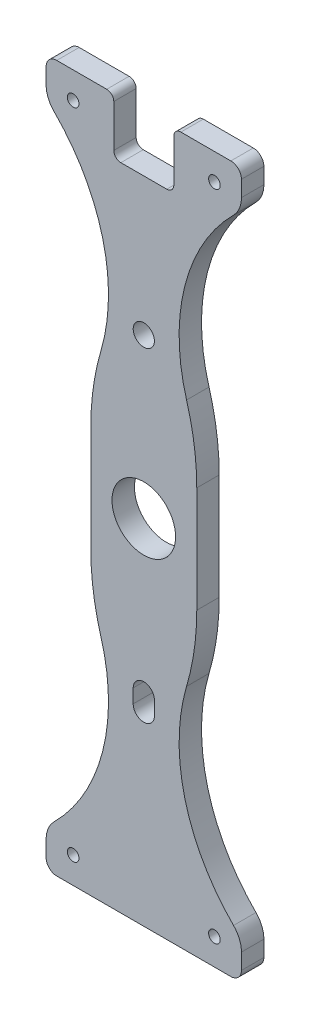
from build123d import *

# Parameters (mm, degrees)
SKETCH1_R           = 9
SKETCH1_R_2         = 3
SKETCH1_R_3         = 1.65
BOSS_EXTRUDE1_DEPTH = 6.35
CUT_EXTRUDE1_DEPTH  = 10
FILLET1_R           = 2


with BuildPart() as part:
    # Sketch1 → Boss-Extrude1 (new body)
    with BuildSketch(Plane.XY):
        with BuildLine():
            Line((-15, 15), (-15, -15))
            ThreePointArc((-15, -15), (-14.275727836, -25.159324804), (-12.117561222, -35.113156605))
            ThreePointArc((-12.117561222, -35.113156605), (-11.640196728, -62.923473964), (-25.409366876, -87.090633124))
            ThreePointArc((-25.409366876, -87.090633124), (-27.067678424, -89.572471742), (-27.65, -92.5))
            Line((-27.65, -92.5), (-27.65, -97))
            ThreePointArc((-27.65, -97), (-26.771320344, -99.121320344), (-24.65, -100))
            Line((-24.65, -100), (24.65, -100))
            ThreePointArc((24.65, -100), (26.771320344, -99.121320344), (27.65, -97))
            Line((27.65, -97), (27.65, -92.5))
            ThreePointArc((27.65, -92.5), (27.067678424, -89.572471742), (25.409366876, -87.090633124))
            ThreePointArc((25.409366876, -87.090633124), (11.640196728, -62.923473964), (12.117561222, -35.113156605))
            ThreePointArc((12.117561222, -35.113156605), (14.275727836, -25.159324804), (15, -15))
            Line((15, -15), (15, 15))
            ThreePointArc((15, 15), (14.275727836, 25.159324804), (12.117561222, 35.113156605))
            ThreePointArc((12.117561222, 35.113156605), (11.640196728, 62.923473964), (25.409366876, 87.090633124))
            ThreePointArc((25.409366876, 87.090633124), (27.067678424, 89.572471742), (27.65, 92.5))
            Line((27.65, 92.5), (27.65, 97))
            ThreePointArc((27.65, 97), (26.771320344, 99.121320344), (24.65, 100))
            Line((24.65, 100), (-24.65, 100))
            ThreePointArc((-24.65, 100), (-26.771320344, 99.121320344), (-27.65, 97))
            Line((-27.65, 97), (-27.65, 92.5))
            ThreePointArc((-27.65, 92.5), (-27.067678424, 89.572471742), (-25.409366876, 87.090633124))
            ThreePointArc((-25.409366876, 87.090633124), (-11.640196728, 62.923473964), (-12.117561222, 35.113156605))
            ThreePointArc((-12.117561222, 35.113156605), (-14.275727836, 25.159324804), (-15, 15))
        make_face()
        Circle(SKETCH1_R, mode=Mode.SUBTRACT)
        with Locations((0, 44.9961)):
            Circle(SKETCH1_R_2, mode=Mode.SUBTRACT)
        with Locations((20, 92.5)):
            Circle(SKETCH1_R_3, mode=Mode.SUBTRACT)
        with Locations((-20, 92.5)):
            Circle(SKETCH1_R_3, mode=Mode.SUBTRACT)
        with Locations((-20, -92.5)):
            Circle(SKETCH1_R_3, mode=Mode.SUBTRACT)
        with Locations((20, -92.5)):
            Circle(SKETCH1_R_3, mode=Mode.SUBTRACT)
        with BuildLine():
            Line((3, -43.0351625), (3, -46.9570375))
            ThreePointArc((3, -46.9570375), (0, -49.9570375), (-3, -46.9570375))
            Line((-3, -46.9570375), (-3, -43.0351625))
            ThreePointArc((-3, -43.0351625), (0, -40.0351625), (3, -43.0351625))
        make_face(mode=Mode.SUBTRACT)
    extrude(amount=BOSS_EXTRUDE1_DEPTH)

    # Sketch3 → Cut-Extrude1 (cut)
    with BuildSketch(Plane.XY.offset(6.35)):
        with BuildLine():
            Line((-8.5, 101), (-8.5, 86))
            ThreePointArc((-8.5, 86), (-7.914213562, 84.585786438), (-6.5, 84))
            Line((-6.5, 84), (6.5, 84))
            ThreePointArc((6.5, 84), (7.914213562, 84.585786438), (8.5, 86))
            Line((8.5, 86), (8.5, 101))
            Line((8.5, 101), (-8.5, 101))
        make_face()
    extrude(amount=-CUT_EXTRUDE1_DEPTH, mode=Mode.SUBTRACT)

    # Fillet1
    fillet1_edges = [part.edges().sort_by_distance(p)[0] for p in [
        (-8.5, 100, 3.175),
        (8.5, 100, 3.175),
    ]]
    fillet(fillet1_edges, radius=FILLET1_R)


solid = part.part
